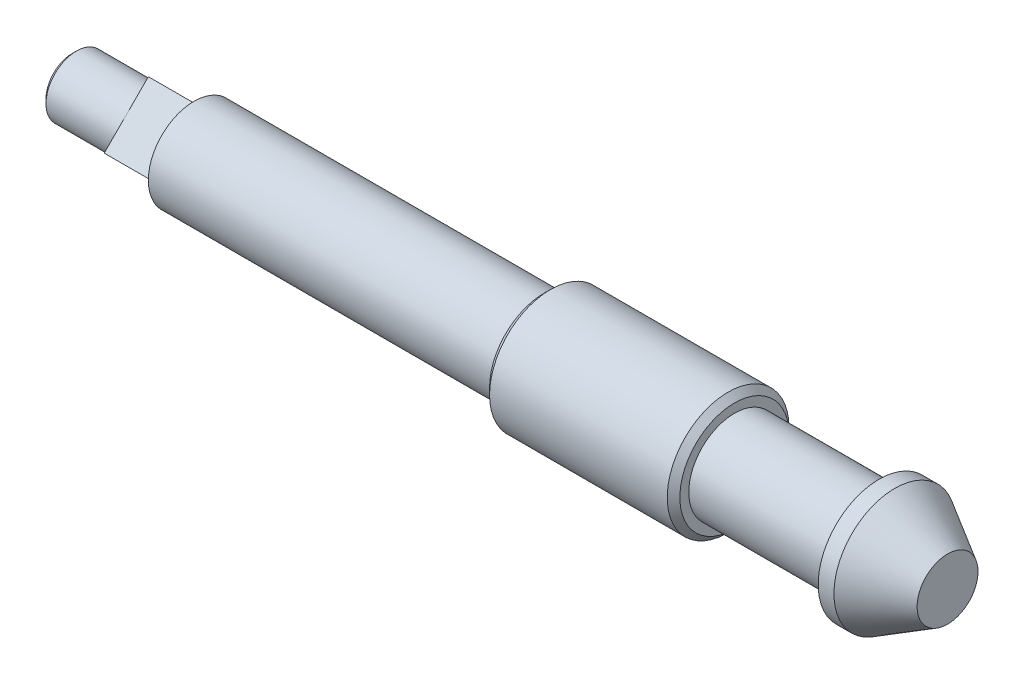
from build123d import *

# Parameters (mm, degrees)
CHAMFER_1_SIZE      = 0.828
SKETCH_2_R          = 6
SKETCH_2_R_2        = 4
CUT_EXTRUDE_1_DEPTH = 10
SKETCH_3_R          = 6
CUT_EXTRUDE_2_DEPTH = 6
CHAMFER_2_SIZE      = 0.5545


with BuildPart() as part:
    # Эскиз1 → Повернуть1 (revolve)
    with BuildSketch(Plane.XY):
        Polygon((0, 0), (0, 4), (-6.92820323, 8), (-9, 8), (-9, 6), (-28, 6), (-28, 8), (-53, 8), (-53, 6), (-115, 6), (-115, 0), align=None)
    revolve(axis=Axis((0, 0, 0), (-1, 0, 0)))

    # Фаска1
    chamfer_1_edges = [part.edges().sort_by_distance(p)[0] for p in [
        (-53, -8, 0),
        (-28, -8, 0),
    ]]
    chamfer(chamfer_1_edges, length=CHAMFER_1_SIZE)

    # Эскиз2 → Вырез-Вытянуть1 (cut)
    with BuildSketch(Plane.ZY.offset(115)):
        Circle(SKETCH_2_R)
        Circle(SKETCH_2_R_2, mode=Mode.SUBTRACT)
    extrude(amount=-CUT_EXTRUDE_1_DEPTH, mode=Mode.SUBTRACT)

    # Эскиз3 → Вырез-Вытянуть2 (cut)
    with BuildSketch(Plane.ZY.offset(105)):
        Circle(SKETCH_3_R)
        Polygon((0, 5.798275606), (-5.798275606, 0), (0, -5.798275606), (5.798275606, 0), align=None, mode=Mode.SUBTRACT)
    extrude(amount=-CUT_EXTRUDE_2_DEPTH, mode=Mode.SUBTRACT)

    # Фаска2
    chamfer_2_edges = [part.edges().sort_by_distance(p)[0] for p in [
        (-115, 0, -4),
    ]]
    chamfer(chamfer_2_edges, length=CHAMFER_2_SIZE)


solid = part.part
